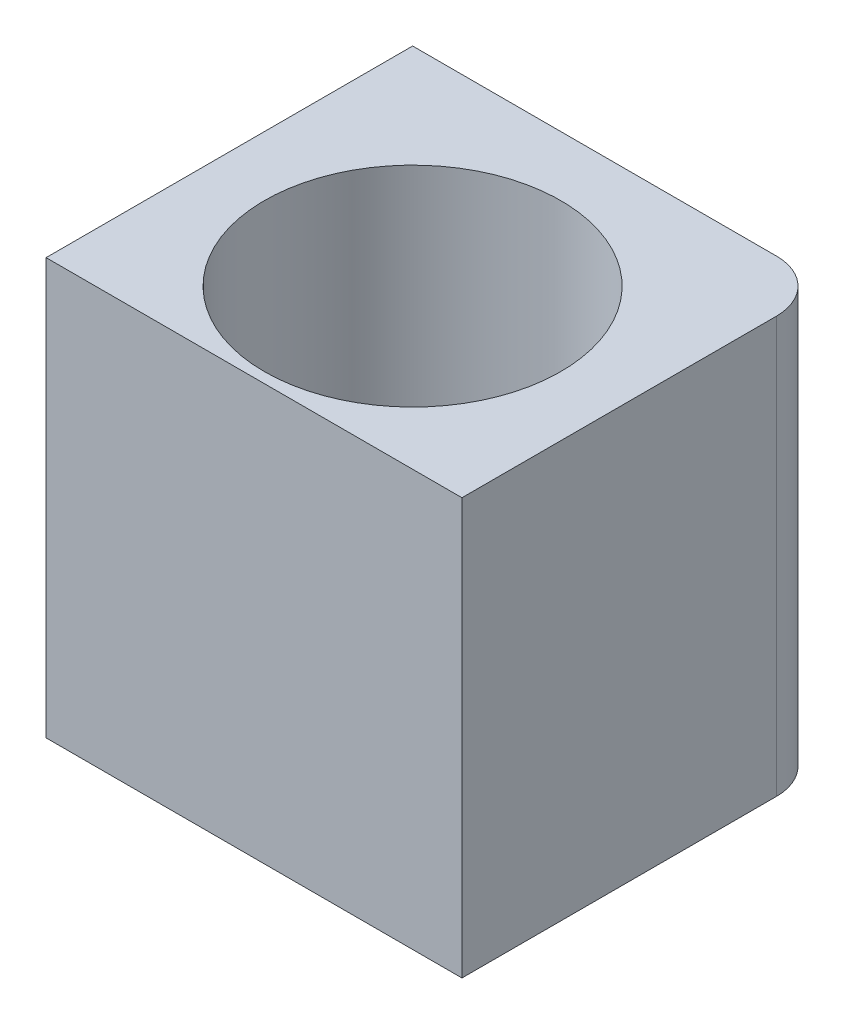
from build123d import *

# Parameters (mm, degrees)
CROQUIS1_R                              = 15.25
CROQUIS1_R_2                            = 2.125
SOPORTE_CAJA_REDUCTORA_DEPTH            = 20
CROQUIS3_R                              = 2.125
CORTAR_EXTRUIR1_DEPTH                   = 51.423828692
REDONDEO1_R                             = 5
BOSS_EXTRUDE1_DEPTH                     = 20
CUT_EXTRUDE1_REACH                      = 55.852
SKETCH2_R                               = 1.625
CUT_EXTRUDE2_DEPTH                      = 2
SKETCH4_R                               = 1.625
CUT_EXTRUDE3_DEPTH                      = 63.291652731
CUT_EXTRUDE4_START                      = -4.5
CUT_EXTRUDE4_DEPTH                      = 2
CROQUIS6_W                              = 4.75
CROQUIS6_H                              = 4.75
CORTAR_EXTRUIR17_DEPTH                  = 42.231056256
CROQUIS7_W                              = 60
CROQUIS7_H                              = 20
CORTAR_EXTRUIR18_DEPTH                  = 51.423828692
SALIENTE_EXTRUIR2_DEPTH                 = 49
SOPORTE_START                           = -15
SOPORTE_MOTOR_DEPTH                     = 15
CROQUIS12_R                             = 2.125
AGUJEROS_DE_SUJECION_A_BASE_DEPTH       = 84.087679592
TUERCA_START                            = -4
TUERCA_AGUJERO_DE_SUJECION_A_BASE_DEPTH = 10
SALIENTE_EXTRUIR4_DEPTH                 = 15
CORTAR_EXTRUIR19_DEPTH                  = 25
CROQUIS14_W                             = 50
CROQUIS14_H                             = 118
CORTAR_EXTRUIR22_DEPTH                  = 146.556045907
CROQUIS15_W                             = 10
CROQUIS15_H                             = 7
CORTAR_EXTRUIR23_DEPTH                  = 42.231056256
CORTAR_EXTRUIR24_DEPTH                  = 42.231056256
CROQUIS18_W                             = 40
CROQUIS18_H                             = 10
CORTAR_EXTRUIR25_DEPTH                  = 44.27311521
SALIENTE_EXTRUIR5_DEPTH                 = 10
CROQUIS20_R                             = 1
CORTAR_EXTRUIR26_DEPTH                  = 49.229270158
CORTAR_EXTRUIR27_REACH                  = 62.959
CORTAR_EXTRUIR27_END_RADIUS             = 15.25
CROQUIS21_R                             = 1.625
CROQUIS22_R                             = 2.125
CROQUIS22_R_2                           = 1
SALIENTE_EXTRUIR6_DEPTH                 = 10
CROQUIS23_R                             = 1.625
CORTAR_EXTRUIR28_DEPTH                  = 52.269508521
CORTAR_EXTRUIR29_START                  = -3
CORTAR_EXTRUIR29_DEPTH                  = 10
SALIENTE_EXTRUIR7_DEPTH                 = 10
CORTAR_EXTRUIR30_REACH                  = 72.235
CROQUIS27_R                             = 1.625
CORTAR_EXTRUIR31_REACH                  = 75.235
CORTAR_EXTRUIR31_START                  = -3
CORTAR_EXTRUIR32_REACH                  = 58.612
CROQUIS29_R                             = 1.625
CORTAR_EXTRUIR33_REACH                  = 61.112
CORTAR_EXTRUIR33_START                  = -2.5
CROQUIS35_W                             = 13.305418987
CROQUIS35_H                             = 6.826864192
CORTAR_EXTRUIR34_DEPTH                  = 63.931555098
CORTAR_EXTRUIR34_DEPTH_BACK             = 63.931555098
CORTAR_EXTRUIR35_START                  = -3
CORTAR_EXTRUIR35_DEPTH                  = 10
SALIENTE_EXTRUIR8_DEPTH                 = 10
SALIENTE_EXTRUIR9_DEPTH                 = 13
SALIENTE_EXTRUIR10_DEPTH                = 3
CROQUIS40_W                             = 106.583537839
CROQUIS40_H                             = 47.391515964
CORTAR_EXTRUIR36_DEPTH                  = 80.887064817
CORTAR_EXTRUIR36_DEPTH_BACK             = 80.887064817
CORTAR_EXTRUIR37_DEPTH                  = 67.2524009
CORTAR_EXTRUIR37_DEPTH_BACK             = 67.2524009
CORTAR_EXTRUIR38_DEPTH                  = 79.704784639
CORTAR_EXTRUIR38_DEPTH_BACK             = 79.704784639
SALIENTE_EXTRUIR11_DEPTH                = 10
CORTAR_EXTRUIR39_DEPTH                  = 63.9908649
CROQUIS45_W                             = 31.470301378
CROQUIS45_H                             = 10
CROQUIS45_R                             = 1.625
SALIENTE_EXTRUIR12_DEPTH                = 2.5
SALIENTE_EXTRUIR13_DEPTH                = 10
CORTAR_EXTRUIR40_START                  = -2
CROQUIS47_R                             = 1.625
CORTAR_EXTRUIR40_DEPTH                  = 10
CORTAR_EXTRUIR41_START                  = -12
CROQUIS48_R                             = 1.625
CORTAR_EXTRUIR41_DEPTH                  = 12
CROQUIS49_W                             = 34.796066513
CROQUIS49_H                             = 42.211026982
CORTAR_EXTRUIR42_DEPTH                  = 52.795622989
CORTAR_EXTRUIR42_DEPTH_BACK             = 52.795622989
CROQUIS51_R                             = 15.25
CROQUIS51_R_2                           = 14.25
SALIENTE_EXTRUIR14_DEPTH                = 10
CORTAR_EXTRUIR43_DEPTH                  = 10
CORTAR_EXTRUIR44_DEPTH                  = 10
CORTAR_EXTRUIR45_DEPTH                  = 10
SALIENTE_EXTRUIR15_DEPTH                = 10
CROQUIS56_R                             = 14.25
SALIENTE_EXTRUIR16_DEPTH                = 40
CROQUIS57_W                             = 35.25
CROQUIS57_H                             = 10
CORTAR_EXTRUIR46_DEPTH                  = 84.0631572
CORTAR_EXTRUIR46_DEPTH_BACK             = 84.0631572


with BuildPart() as part:
    # Croquis1 → Soporte caja reductora (new body)
    with BuildSketch(Plane(origin=(0, 0, 0), x_dir=(1, 0, 0), z_dir=(0, 1, 0))):
        Polygon((-30, -15.25), (-20, -15.25), (-20, -20), (20, -20), (20, -15.25), (30, -15.25), (30, -7.25), (20, -4.25), (20, 20), (-20, 20), (-20, -4.25), (-30, -7.25), align=None)
        with Locations(Location((0, 0, 0), (0, 0, 270))):
            Circle(CROQUIS1_R, mode=Mode.SUBTRACT)
        with Locations(Location((-15, 15, 0), (0, 0, 270))):
            Circle(CROQUIS1_R_2, mode=Mode.SUBTRACT)
        with Locations(Location((15, 15, 0), (0, 0, 270))):
            Circle(CROQUIS1_R_2, mode=Mode.SUBTRACT)
    extrude(amount=-SOPORTE_CAJA_REDUCTORA_DEPTH)

    # Croquis3 → Cortar-Extruir1 (cut, through all)
    with BuildSketch(Plane.XY.offset(15.25)):
        with Locations((-23.5, -10)):
            Circle(CROQUIS3_R)
        with Locations((23.5, -10)):
            Circle(CROQUIS3_R)
    extrude(amount=-CORTAR_EXTRUIR1_DEPTH, mode=Mode.SUBTRACT)

    # Redondeo1
    redondeo1_edges = [part.edges().sort_by_distance(p)[0] for p in [
        (-20, -10, -20),
        (20, -10, -20),
    ]]
    fillet(redondeo1_edges, radius=REDONDEO1_R)

    # Sketch1 → Boss-Extrude1 (add)
    with BuildSketch(Plane(origin=(0, 0, 0), x_dir=(1, 0, 0), z_dir=(0, 1, 0))):
        with BuildLine():
            Line((25.5, 15), (20, 15))
            ThreePointArc((20, 15), (18.535533906, 18.535533906), (15, 20))
            Line((15, 20), (30, 20))
            Line((30, 20), (30, 8))
            Line((30, 8), (25.5, 8))
            Line((25.5, 8), (25.5, 15))
        make_face()
    extrude(amount=-BOSS_EXTRUDE1_DEPTH)

    # Sketch2 → Cut-Extrude1 (cut, up to next)
    with BuildSketch(Plane(origin=(0, 0, -20), x_dir=(-1, 0, 0), z_dir=(0, 0, -1)), mode=Mode.PRIVATE) as cut_extrude1_sk1:
        with Locations((-22.75, -10)):
            Circle(SKETCH2_R)
    cut_extrude1_tool1 = extrude(cut_extrude1_sk1.sketch, amount=-CUT_EXTRUDE1_REACH, mode=Mode.PRIVATE) & part.part
    add(cut_extrude1_tool1.solids().sort_by_distance((22.75, -10, -20))[0], mode=Mode.SUBTRACT)

    # Sketch3 → Cut-Extrude2 (cut)
    with BuildSketch(Plane.XY.offset(-15)):
        Polygon((20, -11.58771324), (22.75, -13.175426481), (25.5, -11.58771324), (25.5, -8.41228676), (22.75, -6.824573519), (20, -8.41228676), align=None)
    extrude(amount=-CUT_EXTRUDE2_DEPTH, mode=Mode.SUBTRACT)

    # Sketch4 → Cut-Extrude3 (cut, through all)
    with BuildSketch(Plane.ZY.offset(-25.5)):
        with Locations((-12.25, -10)):
            Circle(SKETCH4_R)
    extrude(amount=-CUT_EXTRUDE3_DEPTH, mode=Mode.SUBTRACT)

    # Sketch5 → Cut-Extrude4 (cut)
    with BuildSketch(Plane(origin=(30, 0, 0), x_dir=(0, 0, -1), z_dir=(1, 0, 0)).offset(CUT_EXTRUDE4_START)):
        Polygon((15, -11.58771324), (15, -8.41228676), (12.25, -6.824573519), (9.5, -8.41228676), (9.5, -11.58771324), (12.25, -13.175426481), align=None)
    extrude(amount=CUT_EXTRUDE4_DEPTH, mode=Mode.SUBTRACT)

    # Croquis6 → Cortar-Extruir17 (cut, through all)
    with BuildSketch(Plane(origin=(0, 0, 0), x_dir=(1, 0, 0), z_dir=(0, 1, 0))):
        Polygon((0, -15.25), (-15.25, -15.25), (-15.25, -20), (15.25, -20), (15.25, -15.25), align=None)
        with Locations((-17.625, -17.625)):
            Rectangle(CROQUIS6_W, CROQUIS6_H)
        with BuildLine():
            ThreePointArc((0, -15.25), (-10.783378413, -10.783378413), (-15.25, 0))
            Line((-15.25, 0), (-15.25, -15.25))
            Line((-15.25, -15.25), (0, -15.25))
        make_face()
        with BuildLine():
            Line((15.25, -15.25), (15.25, 0))
            ThreePointArc((15.25, 0), (10.783378413, -10.783378413), (0, -15.25))
            Line((0, -15.25), (15.25, -15.25))
        make_face()
        with Locations((17.625, -17.625)):
            Rectangle(CROQUIS6_W, CROQUIS6_H)
    extrude(amount=-CORTAR_EXTRUIR17_DEPTH, mode=Mode.SUBTRACT)


with BuildPart() as body_2:
    # Simetría1: mirrored copy
    add(part.part.mirror(Plane.ZX))

    # Croquis8 → Saliente-Extruir2 (add)
    with BuildSketch(Plane(origin=(0, 20, 0), x_dir=(1, 0, 0), z_dir=(0, 1, 0))):
        with BuildLine():
            Line((-12.664515522, 20), (-11.040489496, 13.939052358))
            Line((-11.040489496, 13.939052358), (-10.315162126, 11.232093763))
            ThreePointArc((-10.315162126, 11.232093763), (0, 15.25), (10.315162126, 11.232093763))
            Line((10.315162126, 11.232093763), (10.817418481, 13.87928066))
            Line((10.817418481, 13.87928066), (11.978715476, 20))
            Line((11.978715476, 20), (-12.664515522, 20))
        make_face()
    extrude(amount=SALIENTE_EXTRUIR2_DEPTH)

    # Croquis9 → Soporte motor (add)
    with BuildSketch(Plane(origin=(0, 69, 0), x_dir=(1, 0, 0), z_dir=(0, 1, 0)).offset(SOPORTE_START)):
        with BuildLine():
            Line((-20, 15), (-20, -4.25))
            Line((-20, -4.25), (-30, -7.25))
            Line((-30, -7.25), (-30, -15.25))
            Line((-30, -15.25), (0, -15.25))
            Line((0, -15.25), (0, -14.75))
            ThreePointArc((0, -14.75), (-10.429825023, 10.429825023), (14.75, 0))
            Line((14.75, 0), (20, 0))
            Line((20, 0), (20, 13.936837101))
            Line((20, 13.936837101), (12.664515522, 20))
            Line((12.664515522, 20), (-15, 20))
            ThreePointArc((-15, 20), (-18.535533906, 18.535533906), (-20, 15))
        make_face()
    extrude(amount=-SOPORTE_MOTOR_DEPTH)

    # Croquis12 → Agujeros de sujecion a base (cut, through all)
    with BuildSketch(Plane.XY.offset(15.25)):
        with Locations((-23.5, 46.5)):
            Circle(CROQUIS12_R)
    extrude(amount=-AGUJEROS_DE_SUJECION_A_BASE_DEPTH, mode=Mode.SUBTRACT)

    # Croquis13 → Tuerca Agujero de sujecion a base (cut)
    with BuildSketch(Plane.XY.offset(15.25).offset(TUERCA_START)):
        Polygon((-20, 44.479274058), (-20, 48.520725942), (-23.5, 50.541451884), (-27, 48.520725942), (-27, 44.479274058), (-23.5, 42.458548116), align=None)
    extrude(amount=-TUERCA_AGUJERO_DE_SUJECION_A_BASE_DEPTH, mode=Mode.SUBTRACT)

    # Croquis10 → Saliente-Extruir4 (add)
    with BuildSketch(Plane(origin=(0, 69, 0), x_dir=(1, 0, 0), z_dir=(0, 1, 0))):
        with BuildLine():
            ThreePointArc((10.315162126, 11.232093763), (0, 15.25), (-10.315162126, 11.232093763))
            Line((-10.315162126, 11.232093763), (-10.16850369, 10.684757026))
            ThreePointArc((-10.16850369, 10.684757026), (0, 14.75), (10.16850369, 10.684757026))
            Line((10.16850369, 10.684757026), (10.315162126, 11.232093763))
        make_face()
    extrude(amount=-SALIENTE_EXTRUIR4_DEPTH)

    # Croquis11 → Cortar-Extruir19 (cut)
    with BuildSketch(Plane.XZ):
        with BuildLine():
            Line((15.25, 4.25), (20, 4.25))
            Line((20, 4.25), (21.972856468, 4.84185694))
            ThreePointArc((21.972856468, 4.84185694), (19.948931102, 10.40625523), (16.543503257, 15.25))
            Line((16.543503257, 15.25), (15.25, 15.25))
            Line((15.25, 15.25), (15.25, 4.25))
        make_face()
        with BuildLine():
            Line((21.972856468, 4.84185694), (30, 7.25))
            Line((30, 7.25), (30, 15.25))
            Line((30, 15.25), (16.543503257, 15.25))
            ThreePointArc((16.543503257, 15.25), (19.948931102, 10.40625523), (21.972856468, 4.84185694))
        make_face()
        with BuildLine():
            ThreePointArc((20, -15), (18.535533906, -18.535533906), (15, -20))
            Line((15, -20), (30, -20))
            Line((30, -20), (30, -8))
            Line((30, -8), (25.5, -8))
            Line((25.5, -8), (25.5, -15))
            Line((25.5, -15), (20, -15))
        make_face()
    extrude(amount=-CORTAR_EXTRUIR19_DEPTH, mode=Mode.SUBTRACT)

    # Simetría2: body 2 across face


with BuildPart() as part_1:
    add(part.part)

    # Croquis7 → Cortar-Extruir18 (cut, through all)
    with BuildSketch(Plane(origin=(0, 0, -20), x_dir=(-1, 0, 0), z_dir=(0, 0, -1))):
        with Locations((0, -10)):
            Rectangle(CROQUIS7_W, CROQUIS7_H)
    extrude(amount=-CORTAR_EXTRUIR18_DEPTH, mode=Mode.SUBTRACT)


with BuildPart() as body_2_1:
    add(body_2.part)
    add(body_2.part.mirror(Plane(origin=(-0.229209569, 69, -16.663998028), x_dir=(0, 0, 1), z_dir=(0, 1, 0))))

    # Croquis14 → Cortar-Extruir22 (cut, through all)
    with BuildSketch(Plane.XY.offset(15.25)):
        with Locations((-5, 79)):
            Rectangle(CROQUIS14_W, CROQUIS14_H)
    extrude(amount=-CORTAR_EXTRUIR22_DEPTH, mode=Mode.SUBTRACT)

    # Croquis15 → Cortar-Extruir23 (cut, through all)
    with BuildSketch(Plane.XZ):
        with Locations((-25, 7.75)):
            Rectangle(CROQUIS15_W, CROQUIS15_H)
    extrude(amount=-CORTAR_EXTRUIR23_DEPTH, mode=Mode.SUBTRACT)

    # Croquis16 → Cortar-Extruir24 (cut, through all)
    with BuildSketch(Plane.XZ):
        Polygon((-30, 15.25), (-15.25, 15.25), (-15.25, 12.75), (-20, 12.75), (-20, 11.25), (-30, 11.25), (-30, 12.75), align=None)
    extrude(amount=-CORTAR_EXTRUIR24_DEPTH, mode=Mode.SUBTRACT)

    # Croquis18 → Cortar-Extruir25 (cut, through all)
    with BuildSketch(Plane(origin=(0, 0, -20), x_dir=(-1, 0, 0), z_dir=(0, 0, -1))):
        with Locations((0, 5)):
            Rectangle(CROQUIS18_W, CROQUIS18_H)
    extrude(amount=-CORTAR_EXTRUIR25_DEPTH, mode=Mode.SUBTRACT)

    # Croquis19 → Saliente-Extruir5 (add)
    with BuildSketch(Plane(origin=(0, 20, 0), x_dir=(1, 0, 0), z_dir=(0, 1, 0))):
        Polygon((-20, -12.75), (-34, -12.75), (-34, -7.75), (-24, -7.75), (-20, -3.75), align=None)
    extrude(amount=-SALIENTE_EXTRUIR5_DEPTH)

    # Croquis20 → Cortar-Extruir26 (cut, through all)
    with BuildSketch(Plane(origin=(0, 0, 7.75), x_dir=(-1, 0, 0), z_dir=(0, 0, -1))):
        with Locations((29, 15)):
            Circle(CROQUIS20_R)
    extrude(amount=-CORTAR_EXTRUIR26_DEPTH, mode=Mode.SUBTRACT)

    # Cortar-Extruir27: up to this cylinder (the profile starts outside it)
    cortar_extruir27_end = Plane(origin=(0, 15, 0), z_dir=(0, -1, 0)) * Cylinder(CORTAR_EXTRUIR27_END_RADIUS, 157.418, mode=Mode.PRIVATE)
    # Croquis21 → Cortar-Extruir27 (cut, up to the surface)
    with BuildSketch(Plane(origin=(20, 0, 0), x_dir=(0, 0, -1), z_dir=(1, 0, 0)), mode=Mode.PRIVATE) as cortar_extruir27_sk1:
        with Locations((4.75, 15)):
            Circle(CROQUIS21_R)
    cortar_extruir27_tool1 = extrude(cortar_extruir27_sk1.sketch, amount=-CORTAR_EXTRUIR27_REACH, mode=Mode.PRIVATE) - cortar_extruir27_end
    add(cortar_extruir27_tool1.solids().sort_by_distance((20, 15, -4.75))[0], mode=Mode.SUBTRACT)

    # Croquis22 → Saliente-Extruir6 (add)
    with BuildSketch(Plane.XZ.offset(-10)):
        with Locations((-15, -15)):
            Circle(CROQUIS22_R)
        with Locations(Location((-15, -15, 0), (0, 0, 270))):
            Circle(CROQUIS22_R_2, mode=Mode.SUBTRACT)
        with Locations((15, -15)):
            Circle(CROQUIS22_R)
        with Locations(Location((15, -15, 0), (0, 0, 270))):
            Circle(CROQUIS22_R_2, mode=Mode.SUBTRACT)
    extrude(amount=-SALIENTE_EXTRUIR6_DEPTH)

    # Croquis23 → Cortar-Extruir28 (cut, through all)
    with BuildSketch(Plane(origin=(0, 0, -20), x_dir=(-1, 0, 0), z_dir=(0, 0, -1))):
        with Locations((0, 15)):
            Circle(CROQUIS23_R)
    extrude(amount=-CORTAR_EXTRUIR28_DEPTH, mode=Mode.SUBTRACT)

    # Croquis24 → Cortar-Extruir29 (cut)
    with BuildSketch(Plane(origin=(0, 0, -20), x_dir=(-1, 0, 0), z_dir=(0, 0, -1)).offset(CORTAR_EXTRUIR29_START)):
        Polygon((1.58771324, 12.25), (3.175426481, 15), (1.58771324, 17.75), (-1.58771324, 17.75), (-3.175426481, 15), (-1.58771324, 12.25), align=None)
    extrude(amount=-CORTAR_EXTRUIR29_DEPTH, mode=Mode.SUBTRACT)

    # Croquis26 → Saliente-Extruir7 (add)
    with BuildSketch(Plane.XZ.offset(-10)):
        Polygon((-34, 7.75), (-34, 12.75), (-58.825, 12.75), (-39.160527763, -4.104491148), (-20, -4.104491148), (-20, -0.104491148), (-35.732113118, -0.104491148), (-29, 7.75), align=None)
        Polygon((-34.268209086, 7.75), (-39.594516123, 1.535690951), (-46.844874897, 7.75), align=None, mode=Mode.SUBTRACT)
    extrude(amount=-SALIENTE_EXTRUIR7_DEPTH)

    # Croquis27 → Cortar-Extruir30 (cut, up to next)
    with BuildSketch(Plane.XY.offset(12.75), mode=Mode.PRIVATE) as cortar_extruir30_sk1:
        with Locations((-40.544874897, 15)):
            Circle(CROQUIS27_R)
    cortar_extruir30_tool1 = extrude(cortar_extruir30_sk1.sketch, amount=-CORTAR_EXTRUIR30_REACH, mode=Mode.PRIVATE) & body_2_1.part
    # Croquis27 → Cortar-Extruir30 (cut, up to next)
    with BuildSketch(Plane.XY.offset(12.75), mode=Mode.PRIVATE) as cortar_extruir30_sk2:
        with Locations((-29, 15)):
            Circle(CROQUIS27_R)
    cortar_extruir30_tool2 = extrude(cortar_extruir30_sk2.sketch, amount=-CORTAR_EXTRUIR30_REACH, mode=Mode.PRIVATE) & body_2_1.part
    add(cortar_extruir30_tool1.solids().sort_by_distance((-40.544875, 15, 12.75))[0], mode=Mode.SUBTRACT)
    add(cortar_extruir30_tool2.solids().sort_by_distance((-29, 15, 12.75))[0], mode=Mode.SUBTRACT)

    # Croquis28 → Cortar-Extruir31 (cut, up to next)
    with BuildSketch(Plane.XY.offset(12.75).offset(CORTAR_EXTRUIR31_START), mode=Mode.PRIVATE) as cortar_extruir31_sk1:
        Polygon((-38.957161657, 12.25), (-37.369448416, 15), (-38.957161657, 17.75), (-42.132588137, 17.75), (-43.720301378, 15), (-42.132588137, 12.25), align=None)
    cortar_extruir31_tool1 = extrude(cortar_extruir31_sk1.sketch, amount=-CORTAR_EXTRUIR31_REACH, mode=Mode.PRIVATE) & body_2_1.part
    # Croquis28 → Cortar-Extruir31 (cut, up to next)
    with BuildSketch(Plane.XY.offset(12.75).offset(CORTAR_EXTRUIR31_START), mode=Mode.PRIVATE) as cortar_extruir31_sk2:
        Polygon((-27.41228676, 12.25), (-25.824573519, 15), (-27.41228676, 17.75), (-30.58771324, 17.75), (-32.175426481, 15), (-30.58771324, 12.25), align=None)
    cortar_extruir31_tool2 = extrude(cortar_extruir31_sk2.sketch, amount=-CORTAR_EXTRUIR31_REACH, mode=Mode.PRIVATE) & body_2_1.part
    add(cortar_extruir31_tool1.solids().sort_by_distance((-40.544875, 15, 9.75))[0], mode=Mode.SUBTRACT)
    add(cortar_extruir31_tool2.solids().sort_by_distance((-29, 15, 9.75))[0], mode=Mode.SUBTRACT)

    # Croquis29 → Cortar-Extruir32 (cut, up to next)
    with BuildSketch(Plane(origin=(-18.612848159, 0, -21.715982563), x_dir=(-0.7592713073348843, 0, 0.6507742172658468), z_dir=(-0.6507742172658468, 0, -0.7592713073348843)), mode=Mode.PRIVATE) as cortar_extruir32_sk1:
        with Locations((33.812368097, 15)):
            Circle(CROQUIS29_R)
    cortar_extruir32_tool1 = extrude(cortar_extruir32_sk1.sketch, amount=-CORTAR_EXTRUIR32_REACH, mode=Mode.PRIVATE) & body_2_1.part
    add(cortar_extruir32_tool1.solids().sort_by_distance((-44.285609, 15, 0.288235))[0], mode=Mode.SUBTRACT)

    # Croquis31 → Cortar-Extruir33 (cut, up to next)
    with BuildSketch(Plane(origin=(-18.612848159, 0, -21.715982563), x_dir=(-0.7592713073348843, 0, 0.6507742172658468), z_dir=(-0.6507742172658468, 0, -0.7592713073348843)).offset(CORTAR_EXTRUIR33_START), mode=Mode.PRIVATE) as cortar_extruir33_sk1:
        Polygon((36.562368097, 16.58771324), (33.812368097, 18.175426481), (31.062368097, 16.58771324), (31.062368097, 13.41228676), (33.812368097, 11.824573519), (36.562368097, 13.41228676), align=None)
    cortar_extruir33_tool1 = extrude(cortar_extruir33_sk1.sketch, amount=-CORTAR_EXTRUIR33_REACH, mode=Mode.PRIVATE) & body_2_1.part
    add(cortar_extruir33_tool1.solids().sort_by_distance((-42.658674, 15, 2.186413))[0], mode=Mode.SUBTRACT)

    # Croquis35 → Cortar-Extruir34 (cut, two sides)
    with BuildSketch(Plane(origin=(0, 20, 0), x_dir=(1, 0, 0), z_dir=(0, 1, 0))) as cortar_extruir34_sk:
        with Locations((17.04227466, -3.413432096)):
            Rectangle(CROQUIS35_W, CROQUIS35_H)
    extrude(amount=CORTAR_EXTRUIR34_DEPTH, mode=Mode.SUBTRACT)
    extrude(cortar_extruir34_sk.sketch, amount=-CORTAR_EXTRUIR34_DEPTH_BACK, mode=Mode.SUBTRACT)

    # Croquis36 → Cortar-Extruir35 (cut)
    with BuildSketch(Plane(origin=(20, 0, 0), x_dir=(0, 0, -1), z_dir=(1, 0, 0)).offset(CORTAR_EXTRUIR35_START)):
        Polygon((7.5, 16.58771324), (4.75, 18.175426481), (2, 16.58771324), (2, 13.41228676), (4.75, 11.824573519), (7.5, 13.41228676), align=None)
    extrude(amount=-CORTAR_EXTRUIR35_DEPTH, mode=Mode.SUBTRACT)

    # Croquis37 → Saliente-Extruir8 (add)
    with BuildSketch(Plane.XZ.offset(-10)):
        Polygon((-39.160527763, -4.104491148), (-20.614919368, -20), (-15, -20), (-19.558128305, -15.637570403), (-33.014002756, -4.104491148), align=None)
    extrude(amount=-SALIENTE_EXTRUIR8_DEPTH)

    # Croquis38 → Saliente-Extruir9 (add)
    with BuildSketch(Plane.XZ.offset(-10)):
        Polygon((-58.825, 12.75), (-38.825, 12.75), (-38.825, 9.75), (-55.324839942, 9.75), align=None)
    extrude(amount=SALIENTE_EXTRUIR9_DEPTH)

    # Croquis39 → Saliente-Extruir10 (add)
    with BuildSketch(Plane.XZ.offset(-10)):
        Polygon((-38.825, 9.75), (-38.825, 7.75), (-38.825, 5.75), (-50.657959865, 5.75), (-52.991399903, 7.75), (-55.324839942, 9.75), align=None)
    extrude(amount=SALIENTE_EXTRUIR10_DEPTH)

    # Simetría3: body 2 across face


with BuildPart() as body_2_2:
    add(body_2_1.part)
    add(body_2_1.part.mirror(Plane(origin=(-18.003999227, 20, -4.220503046), x_dir=(0, 0, 1), z_dir=(0, 1, 0))))

    # Croquis40 → Cortar-Extruir36 (cut, two sides)
    with BuildSketch(Plane(origin=(0, 0, -20), x_dir=(-1, 0, 0), z_dir=(0, 0, -1))) as cortar_extruir36_sk:
        with Locations((22.395502026, -3.695757982)):
            Rectangle(CROQUIS40_W, CROQUIS40_H)
    extrude(amount=CORTAR_EXTRUIR36_DEPTH, mode=Mode.SUBTRACT)
    extrude(cortar_extruir36_sk.sketch, amount=-CORTAR_EXTRUIR36_DEPTH_BACK, mode=Mode.SUBTRACT)

    # Croquis41 → Cortar-Extruir37 (cut, two sides)
    with BuildSketch(Plane.XZ.offset(-20)) as cortar_extruir37_sk:
        Polygon((-19.992980133, -22.302484261), (-20, 3.75), (-24, 7.75), (-56.035110209, 7.75), align=None)
    extrude(amount=CORTAR_EXTRUIR37_DEPTH, mode=Mode.SUBTRACT)
    extrude(cortar_extruir37_sk.sketch, amount=-CORTAR_EXTRUIR37_DEPTH_BACK, mode=Mode.SUBTRACT)

    # Croquis42 → Cortar-Extruir38 (cut, two sides)
    with BuildSketch(Plane(origin=(0, 0, 9.75), x_dir=(-1, 0, 0), z_dir=(0, 0, -1))) as cortar_extruir38_sk:
        Polygon((46.720301378, 20), (46.720301378, 30), (38.825, 30), (33.492952769, 43.760628779), (49.525340398, 48.951442806), (67.200390695, 42.512205152), (65.906601328, 20), (51.713995885, 13.864168239), align=None)
    extrude(amount=CORTAR_EXTRUIR38_DEPTH, mode=Mode.SUBTRACT)
    extrude(cortar_extruir38_sk.sketch, amount=-CORTAR_EXTRUIR38_DEPTH_BACK, mode=Mode.SUBTRACT)

    # Croquis43 → Saliente-Extruir11 (add)
    with BuildSketch(Plane.XZ.offset(-20)):
        Polygon((-19.993600539, -20), (-46.720301378, 7.75), (-43.839252857, 10.524807997), (-17.112552018, -17.225192003), align=None)
    extrude(amount=-SALIENTE_EXTRUIR11_DEPTH)

    # Croquis44 → Cortar-Extruir39 (cut, through all)
    with BuildSketch(Plane(origin=(0, 0, 9.75), x_dir=(-1, 0, 0), z_dir=(0, 0, -1))):
        Polygon((38.957161657, 27.75), (37.369448416, 25), (38.957161657, 22.25), (42.132588137, 22.25), (43.720301378, 25), (42.132588137, 27.75), align=None)
    extrude(amount=CORTAR_EXTRUIR39_DEPTH, mode=Mode.SUBTRACT)

    # Croquis45 → Saliente-Extruir12 (add)
    with BuildSketch(Plane.XY.offset(12.75)):
        with Locations((-30.985150689, 25)):
            Rectangle(CROQUIS45_W, CROQUIS45_H)
        with Locations((-40.544874897, 25)):
            Circle(CROQUIS45_R, mode=Mode.SUBTRACT)
        with Locations((-29, 25)):
            Circle(CROQUIS45_R, mode=Mode.SUBTRACT)
    extrude(amount=SALIENTE_EXTRUIR12_DEPTH)

    # Croquis46 → Saliente-Extruir13 (add)
    with BuildSketch(Plane.XZ.offset(-20)):
        with BuildLine():
            Line((15.25, 0), (20, 0))
            Line((20, 0), (20, 15.25))
            Line((20, 15.25), (7.549834435, 15.25))
            Line((7.549834435, 15.25), (7.549834435, 13.25))
            ThreePointArc((7.549834435, 13.25), (13.185171124, 7.662490615), (15.25, 0))
        make_face()
        with BuildLine():
            Line((-15.25, 0), (-15.25, 15.25))
            Line((-15.25, 15.25), (-7.549834435, 15.25))
            Line((-7.549834435, 15.25), (-7.549834435, 13.25))
            ThreePointArc((-7.549834435, 13.25), (-13.185171124, 7.662490615), (-15.25, 0))
        make_face()
    extrude(amount=-SALIENTE_EXTRUIR13_DEPTH)

    # Croquis47 → Cortar-Extruir40 (cut)
    with BuildSketch(Plane.XY.offset(15.25).offset(CORTAR_EXTRUIR40_START)):
        Polygon((15.41228676, 22.352505966), (17, 25.102505966), (15.41228676, 27.852505966), (12.236860279, 27.852505966), (10.649147039, 25.102505966), (12.236860279, 22.352505966), align=None)
        with Locations((13.824573519, 25.102505966)):
            Circle(CROQUIS47_R, mode=Mode.SUBTRACT)
        Polygon((-12.236860279, 22.352505966), (-15.41228676, 22.352505966), (-17, 25.102505966), (-15.41228676, 27.852505966), (-12.236860279, 27.852505966), (-10.649147039, 25.102505966), align=None)
        with Locations(Location((-13.824573519, 25.102505966, 0), (0, 0, 131.421584744))):
            Circle(CROQUIS47_R, mode=Mode.SUBTRACT)
    extrude(amount=-CORTAR_EXTRUIR40_DEPTH, mode=Mode.SUBTRACT)

    # Croquis48 → Cortar-Extruir41 (cut)
    with BuildSketch(Plane.XY.offset(15.25).offset(CORTAR_EXTRUIR41_START)):
        with Locations((13.824573519, 25.102505966)):
            Circle(CROQUIS48_R)
        with Locations((-13.824573519, 25.102505966)):
            Circle(CROQUIS48_R)
    extrude(amount=CORTAR_EXTRUIR41_DEPTH, mode=Mode.SUBTRACT)

    # Croquis49 → Cortar-Extruir42 (cut, two sides)
    with BuildSketch(Plane.XZ.offset(-20)) as cortar_extruir42_sk:
        with Locations((-37.391633796, 1.105513491)):
            Rectangle(CROQUIS49_W, CROQUIS49_H)
    extrude(amount=CORTAR_EXTRUIR42_DEPTH, mode=Mode.SUBTRACT)
    extrude(cortar_extruir42_sk.sketch, amount=-CORTAR_EXTRUIR42_DEPTH_BACK, mode=Mode.SUBTRACT)

    # Croquis51 → Saliente-Extruir14 (add)
    with BuildSketch(Plane(origin=(0, 30, 0), x_dir=(1, 0, 0), z_dir=(0, 1, 0))):
        Circle(CROQUIS51_R)
        with Locations(Location((0, 0, 0), (0, 0, 270))):
            Circle(CROQUIS51_R_2, mode=Mode.SUBTRACT)
    extrude(amount=-SALIENTE_EXTRUIR14_DEPTH)

    # Croquis52 → Cortar-Extruir43 (cut)
    with BuildSketch(Plane(origin=(0, 0, 13.25), x_dir=(-1, 0, 0), z_dir=(0, 0, -1))):
        Polygon((-10.649147039, 25.102505966), (-12.236860279, 27.852505966), (-15.41228676, 27.852505966), (-17, 25.102505966), (-15.41228676, 22.352505966), (-12.236860279, 22.352505966), align=None)
        Polygon((17, 25.102505966), (15.41228676, 27.852505966), (12.236860279, 27.852505966), (10.649147039, 25.102505966), (12.236860279, 22.352505966), (15.41228676, 22.352505966), align=None)
    extrude(amount=CORTAR_EXTRUIR43_DEPTH, mode=Mode.SUBTRACT)

    # Croquis53 → Cortar-Extruir44 (cut)
    with BuildSketch(Plane.XY.offset(-17)):
        Polygon((3.175426481, 25), (1.58771324, 27.75), (-1.58771324, 27.75), (-3.175426481, 25), (-1.58771324, 22.25), (1.58771324, 22.25), align=None)
    extrude(amount=CORTAR_EXTRUIR44_DEPTH, mode=Mode.SUBTRACT)

    # Croquis54 → Cortar-Extruir45 (cut)
    with BuildSketch(Plane.ZY.offset(-17)):
        Polygon((-4.75, 28.175426481), (-7.5, 26.58771324), (-7.5, 23.41228676), (-4.75, 21.824573519), (-2, 23.41228676), (-2, 26.58771324), align=None)
    extrude(amount=CORTAR_EXTRUIR45_DEPTH, mode=Mode.SUBTRACT)

    # Croquis55 → Saliente-Extruir15 (add)
    with BuildSketch(Plane(origin=(0, 30, 0), x_dir=(1, 0, 0), z_dir=(0, 1, 0))):
        with BuildLine():
            Line((-7.549834435, -13.25), (-7.549834435, -15.25))
            Line((-7.549834435, -15.25), (0, -15.25))
            ThreePointArc((0, -15.25), (-3.905124838, -14.741522988), (-7.549834435, -13.25))
        make_face()
        with BuildLine():
            ThreePointArc((7.549834435, -13.25), (3.905124838, -14.741522988), (0, -15.25))
            Line((0, -15.25), (7.549834435, -15.25))
            Line((7.549834435, -15.25), (7.549834435, -13.25))
        make_face()
    extrude(amount=-SALIENTE_EXTRUIR15_DEPTH)

    # Croquis56 → Saliente-Extruir16 (add)
    with BuildSketch(Plane(origin=(0, 30, 0), x_dir=(1, 0, 0), z_dir=(0, 1, 0))):
        with BuildLine():
            Line((20, -15.25), (20, 15))
            ThreePointArc((20, 15), (18.535533906, 18.535533906), (15, 20))
            Line((15, 20), (-19.993600539, 20))
            Line((-19.993600539, 20), (-19.993600539, -15.25))
            Line((-19.993600539, -15.25), (20, -15.25))
        make_face()
        with Locations(Location((0, 0, 0), (0, 0, 270))):
            Circle(CROQUIS56_R, mode=Mode.SUBTRACT)
    extrude(amount=SALIENTE_EXTRUIR16_DEPTH)

    # Croquis57 → Cortar-Extruir46 (cut, two sides)
    with BuildSketch(Plane.ZY.offset(19.993600539)) as cortar_extruir46_sk:
        with Locations((-2.375, 25)):
            Rectangle(CROQUIS57_W, CROQUIS57_H)
    extrude(amount=CORTAR_EXTRUIR46_DEPTH, mode=Mode.SUBTRACT)
    extrude(cortar_extruir46_sk.sketch, amount=-CORTAR_EXTRUIR46_DEPTH_BACK, mode=Mode.SUBTRACT)


solid = body_2_2.part
